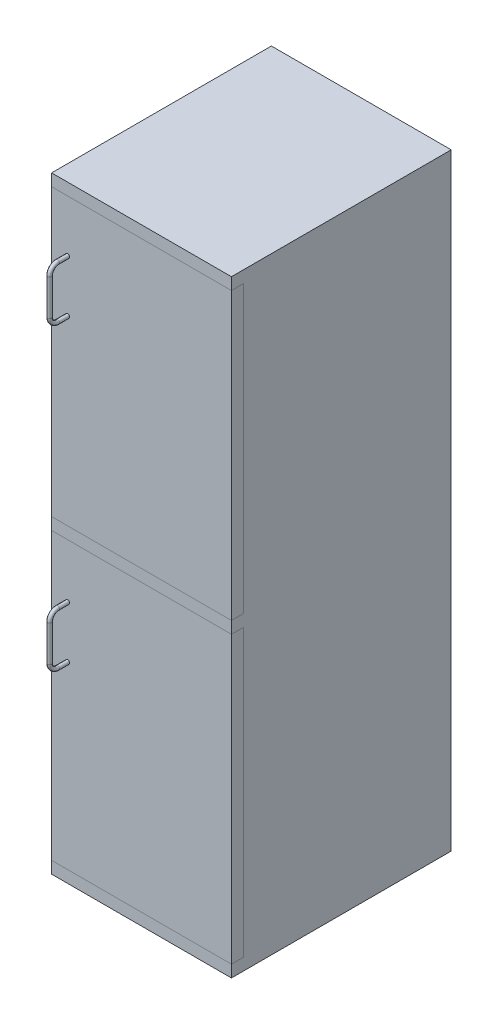
from build123d import *

# Parameters (mm, degrees)
SKETCH1_W             = 450
SKETCH1_H             = 1520
BOSS_EXTRUDE1_DEPTH   = 550
SKETCH2_W             = 450
SKETCH2_H             = 715
CUT_EXTRUDE1_DEPTH    = 30
SKETCH2_2_W           = 450
SKETCH2_2_H           = 715
BOSS_EXTRUDE2_DEPTH   = 30
BOSS_EXTRUDE2_2_DEPTH = 30
SKETCH4_R             = 5
LPATTERN1_COUNT       = 2
LPATTERN1_PITCH       = 750


with BuildPart() as part:
    # Sketch1 → Boss-Extrude1 (new body)
    with BuildSketch(Plane.XY):
        with Locations((225, 760)):
            Rectangle(SKETCH1_W, SKETCH1_H)
    extrude(amount=-BOSS_EXTRUDE1_DEPTH)

    # Sketch2 → Cut-Extrude1 (cut)
    with BuildSketch(Plane.XY):
        with Locations((225, 1132.5)):
            Rectangle(SKETCH2_W, SKETCH2_H)
        with Locations((225, 387.5)):
            Rectangle(SKETCH2_W, SKETCH2_H)
    extrude(amount=-CUT_EXTRUDE1_DEPTH, mode=Mode.SUBTRACT)


with BuildPart() as body_2:
    # Sketch2_2 → Boss-Extrude2 (new body)
    with BuildSketch(Plane.XY):
        with Locations((225, 1132.5)):
            Rectangle(SKETCH2_2_W, SKETCH2_2_H)
    extrude(amount=-BOSS_EXTRUDE2_DEPTH)

    # Sweep5: sweep along a path in Sketch3
    with BuildLine(Plane.ZY.offset(-40)) as sweep5_path:
        Line((0, 1360), (25, 1360))
        ThreePointArc((25, 1360), (39.142135624, 1354.142135624), (45, 1340))
        Line((45, 1340), (45, 1250))
        ThreePointArc((45, 1250), (39.142135624, 1235.857864376), (25, 1230))
        Line((25, 1230), (0, 1230))
    # Sketch4 → Sweep5 (sweep)
    with BuildSketch(Plane.XY):
        with Locations((40, 1360)):
            Circle(SKETCH4_R)
    sweep5 = sweep(path=sweep5_path.line)


with BuildPart() as body_3:
    # Sketch2_2 → Boss-Extrude2 2 (new body)
    with BuildSketch(Plane.XY):
        with Locations((225, 387.5)):
            Rectangle(SKETCH2_2_W, SKETCH2_2_H)
    extrude(amount=-BOSS_EXTRUDE2_2_DEPTH)

    # LPattern1: Sweep5 ×2
    with Locations(*[(0, -i * LPATTERN1_PITCH, 0) for i in range(1, LPATTERN1_COUNT)]):
        add(sweep5)


solid = Compound([part.part, body_2.part, body_3.part])
